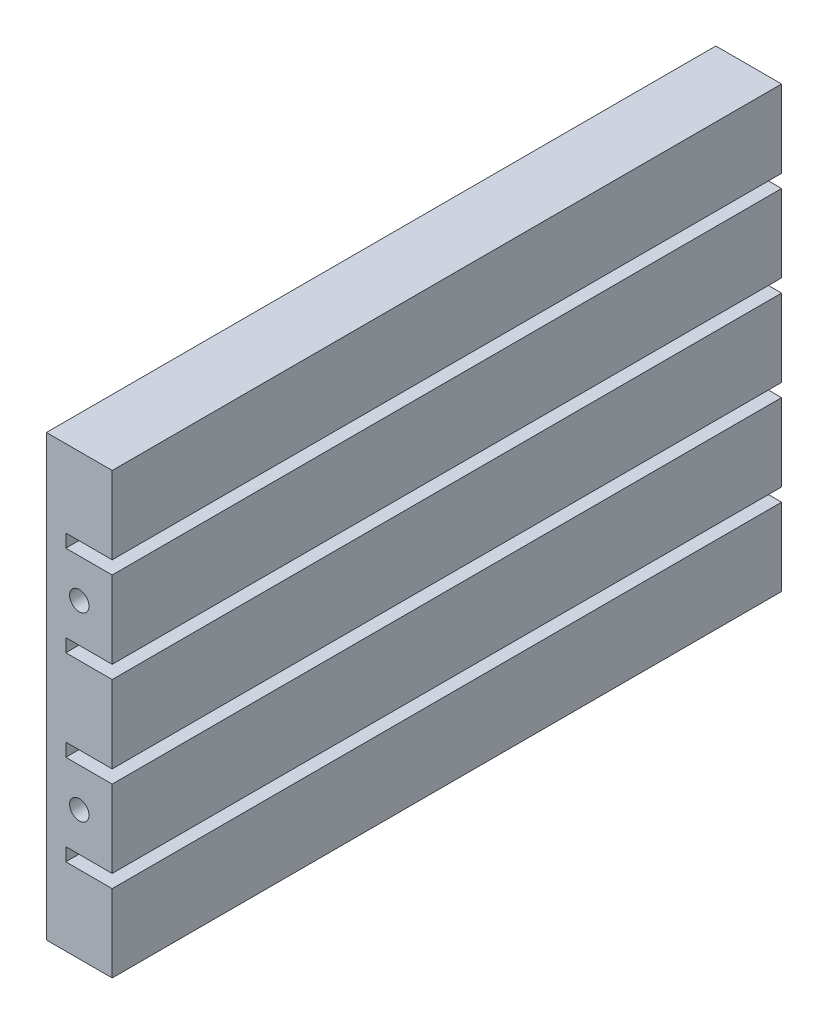
from build123d import *

# Parameters (mm, degrees)
BOSS_EXTRUDE1_DEPTH            = 86.5
M3X0_5_TAPPED_HOLE2_AT_2_COUNT = 2
M3X0_5_TAPPED_HOLE2_AT_2_PITCH = 23.4
M3X0_5_TAPPED_HOLE1_AT_2_COUNT = 2
M3X0_5_TAPPED_HOLE1_AT_2_PITCH = 46.8


with BuildPart() as part:
    # Sketch1 → Boss-Extrude1 (new body)
    with BuildSketch(Plane.XY):
        Polygon((0, 0), (0, 56.8), (8.5, 56.8), (8.5, 46.8), (2.5, 46.8), (2.5, 45.1), (8.5, 45.1), (8.5, 35.1), (2.5, 35.1), (2.5, 33.4), (8.5, 33.4), (8.5, 23.4), (2.5, 23.4), (2.5, 21.7), (8.5, 21.7), (8.5, 11.7), (2.5, 11.7), (2.5, 10), (8.5, 10), (8.5, 0), align=None)
    extrude(amount=BOSS_EXTRUDE1_DEPTH)

    # Sketch4 → M3x0.5 Tapped Hole2 (revolve, cut)
    with BuildSketch(Plane(origin=(4.25, 40.1, 86.5), x_dir=(0, -1, 0), z_dir=(1, 0, 0))):
        Polygon((0, 0), (0, 5.751075774), (1.25, 5), (1.25, 0), align=None)
    m3x0_5_tapped_hole2 = revolve(axis=Axis((4.25, 40.1, 92.85), (0, 0, -1)), mode=Mode.SUBTRACT)

    # M3x0.5 Tapped Hole2 at 2: M3x0.5 Tapped Hole2 ×2
    with Locations(*[(0, -i * M3X0_5_TAPPED_HOLE2_AT_2_PITCH, 0) for i in range(1, M3X0_5_TAPPED_HOLE2_AT_2_COUNT)]):
        add(m3x0_5_tapped_hole2, mode=Mode.SUBTRACT)

    # Mirror1: M3x0.5 Tapped Hole2 across plane
    add(m3x0_5_tapped_hole2.mirror(Plane.XY.offset(43.25)), mode=Mode.SUBTRACT)

    # Mirror1 copy 1 sketch → Mirror1 copy 1 (revolve, cut)
    with BuildSketch(Plane(origin=(4.25, 16.7, 0), x_dir=(0, -1, 0), z_dir=(1, 0, 0))):
        Polygon((0, 0), (0, -5.751075774), (1.25, -5), (1.25, 0), align=None)
    revolve(axis=Axis((4.25, 16.7, -6.35), (0, 0, -1)), mode=Mode.SUBTRACT)

    # Sketch11 → M3x0.5 Tapped Hole1 (revolve, cut)
    with BuildSketch(Plane(origin=(0, 5, 8.25), x_dir=(0, 0, 1), z_dir=(0, 1, 0))):
        Polygon((0, 0), (0, 4.751075774), (1.25, 4), (1.25, 0), align=None)
    m3x0_5_tapped_hole1 = revolve(axis=Axis((-6.35, 5, 8.25), (1, 0, 0)), mode=Mode.SUBTRACT)

    # M3x0.5 Tapped Hole1 at 2: M3x0.5 Tapped Hole1 ×2
    with Locations(*[(0, i * M3X0_5_TAPPED_HOLE1_AT_2_PITCH, 0) for i in range(1, M3X0_5_TAPPED_HOLE1_AT_2_COUNT)]):
        add(m3x0_5_tapped_hole1, mode=Mode.SUBTRACT)

    # Mirror2: M3x0.5 Tapped Hole1 across plane
    add(m3x0_5_tapped_hole1.mirror(Plane(origin=(0, 0, 43.25), x_dir=(1, 0, 0), z_dir=(0, 0, -1))), mode=Mode.SUBTRACT)

    # Mirror2 copy 1 sketch → Mirror2 copy 1 (revolve, cut)
    with BuildSketch(Plane(origin=(0, 51.8, 78.25), x_dir=(0, 0, -1), z_dir=(0, 1, 0))):
        Polygon((0, 0), (0, -4.751075774), (1.25, -4), (1.25, 0), align=None)
    revolve(axis=Axis((-6.35, 51.8, 78.25), (-1, 0, 0)), mode=Mode.SUBTRACT)


solid = part.part
